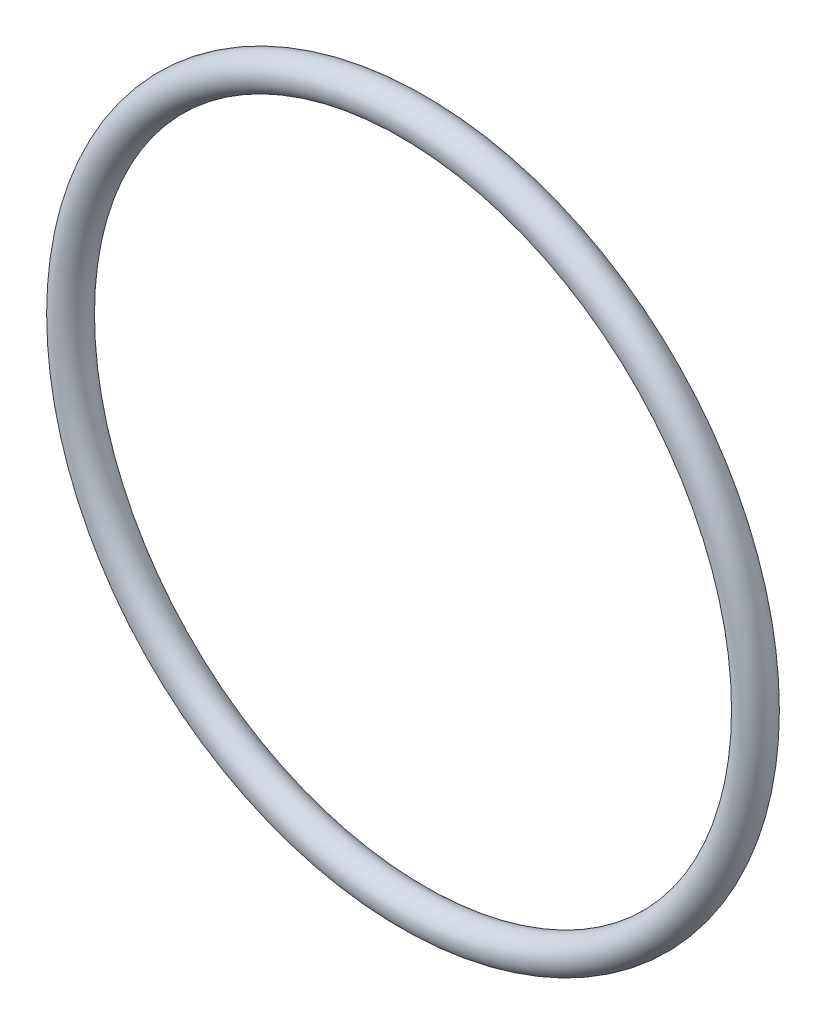
from build123d import *

# Parameters (mm, degrees)
SKETCH2_R = 2.85


with BuildPart() as part:
    # Sweep1: sweep along a path in Sketch1
    with BuildLine(Plane.XY) as sweep1_path:
        CenterArc((0, 0), 54.8, 0, 360)
    # Sketch2 → Sweep1 (sweep)
    with BuildSketch(Plane(origin=(0, 0, 0), x_dir=(1, 0, 0), z_dir=(0, 1, 0))):
        with Locations((-57.65, 0)):
            Circle(SKETCH2_R)
    sweep(path=sweep1_path.line)


solid = part.part
